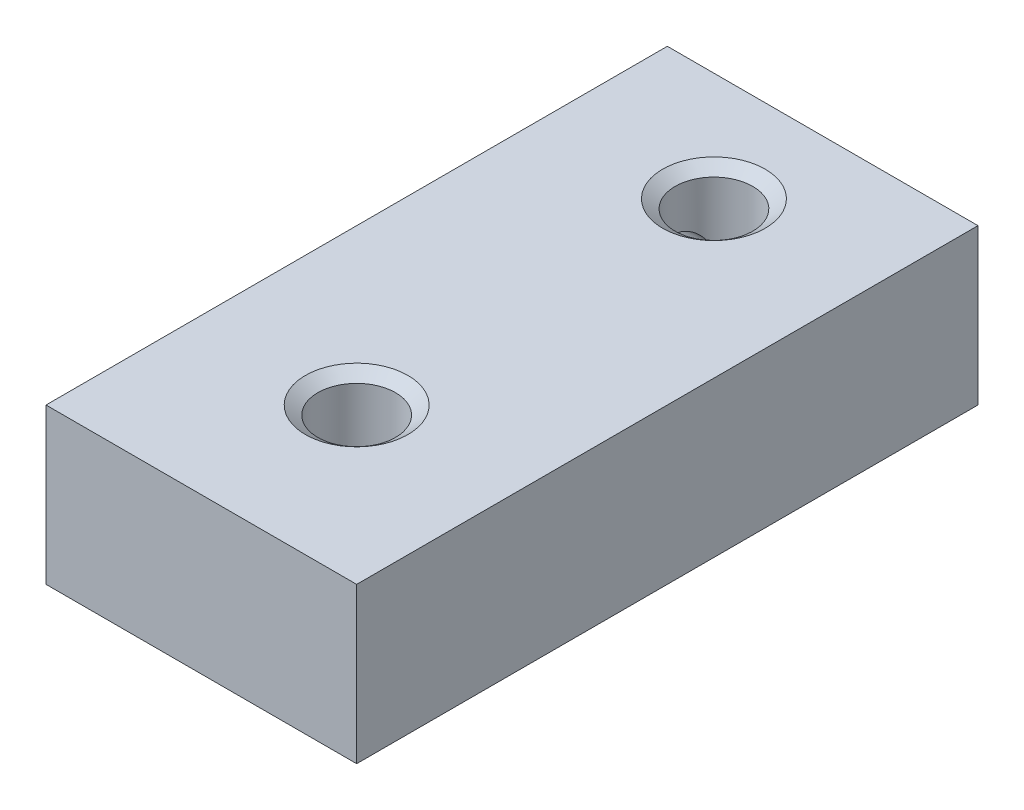
from build123d import *

# Parameters (mm, degrees)
SKETCH_1_W                    = 10
SKETCH_1_H                    = 5
EXTRUDE_1_DEPTH               = 20
M3X0_51_AT_2_COUNT            = 2
M3X0_51_AT_2_PITCH            = 11.5
HOLE_WIZARD_2_561_D           = 1.778
HOLE_WIZARD_2_561_DEPTH       = 5.5
HOLE_WIZARD_2_561_CSINK_D     = 2.54
HOLE_WIZARD_2_561_CSINK_ANGLE = 110
HOLE_WIZARD_2_561_TIP         = 0.53416509


with BuildPart() as part:
    # Эскиз1 → Бобышка-Вытянуть1 (new body)
    with BuildSketch(Plane.XY):
        with Locations((5, 2.5)):
            Rectangle(SKETCH_1_W, SKETCH_1_H)
    extrude(amount=EXTRUDE_1_DEPTH)

    # Эскиз4 → Отверстие обработанное метчиком M3x0.51 (revolve, cut)
    with BuildSketch(Plane(origin=(5, 0, 15), x_dir=(0, 0, -1), z_dir=(1, 0, 0))):
        Polygon((0, 0), (0, 5), (1.65, 5), (1.25, 4.719916985), (1.25, 0.280083015), (1.65, 0), align=None)
    m3x0_51 = revolve(axis=Axis((5, -6.35, 15), (0, 1, 0)), mode=Mode.SUBTRACT)

    # Отверстие обработанное метчиком M3x0.51 at 2: Отверстие обработанное метчиком M3x0.51 ×2
    with Locations(*[(0, 0, -i * M3X0_51_AT_2_PITCH) for i in range(1, M3X0_51_AT_2_COUNT)]):
        add(m3x0_51, mode=Mode.SUBTRACT)

    # Отверстие обработанное метчиком #2-561
    with Locations(Plane.ZY):
        with Locations((3.5, 2.5), (12, 2.5)):
            CounterSinkHole(HOLE_WIZARD_2_561_D / 2, HOLE_WIZARD_2_561_CSINK_D / 2, depth=HOLE_WIZARD_2_561_DEPTH, counter_sink_angle=HOLE_WIZARD_2_561_CSINK_ANGLE)
            with Locations((0, 0, -(HOLE_WIZARD_2_561_DEPTH + HOLE_WIZARD_2_561_TIP / 2))):  # 118° drill point
                Cone(0, HOLE_WIZARD_2_561_D / 2, HOLE_WIZARD_2_561_TIP, mode=Mode.SUBTRACT)


solid = part.part
